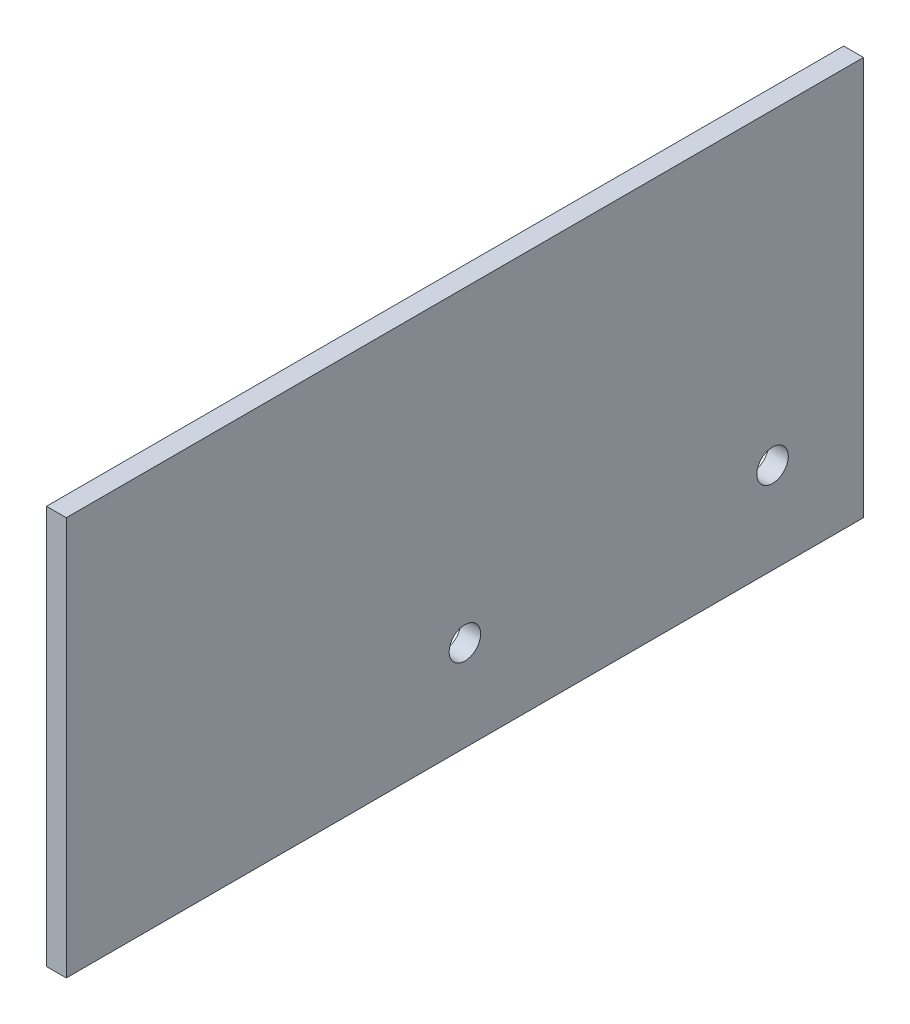
from build123d import *

# Parameters (mm, degrees)
SKETCH1_W               = 181
SKETCH1_H               = 90.5
BOSS_EXTRUDE1_DEPTH     = 2.25
SKETCH2_R               = 3.5687
CUT_EXTRUDE1_DEPTH      = 91.5
CUT_EXTRUDE1_DEPTH_BACK = 1


with BuildPart() as part:
    # Sketch1 → Boss-Extrude1 (new body, symmetric)
    with BuildSketch(Plane(origin=(0, 0, 0), x_dir=(0, 0, -1), z_dir=(1, 0, 0))):
        with Locations((0, -45.25)):
            Rectangle(SKETCH1_W, SKETCH1_H)
    extrude(amount=BOSS_EXTRUDE1_DEPTH, both=True)

    # Sketch2 → Cut-Extrude1 (cut, two sides)
    with BuildSketch(Plane(origin=(-88.25, 0, 0), x_dir=(0, 0, -1), z_dir=(1, 0, 0))) as cut_extrude1_sk:
        with Locations((0, -69.85)):
            Circle(SKETCH2_R)
        with Locations((69.85, -69.85)):
            Circle(SKETCH2_R)
    extrude(amount=CUT_EXTRUDE1_DEPTH, mode=Mode.SUBTRACT)
    extrude(cut_extrude1_sk.sketch, amount=-CUT_EXTRUDE1_DEPTH_BACK, mode=Mode.SUBTRACT)


solid = part.part
